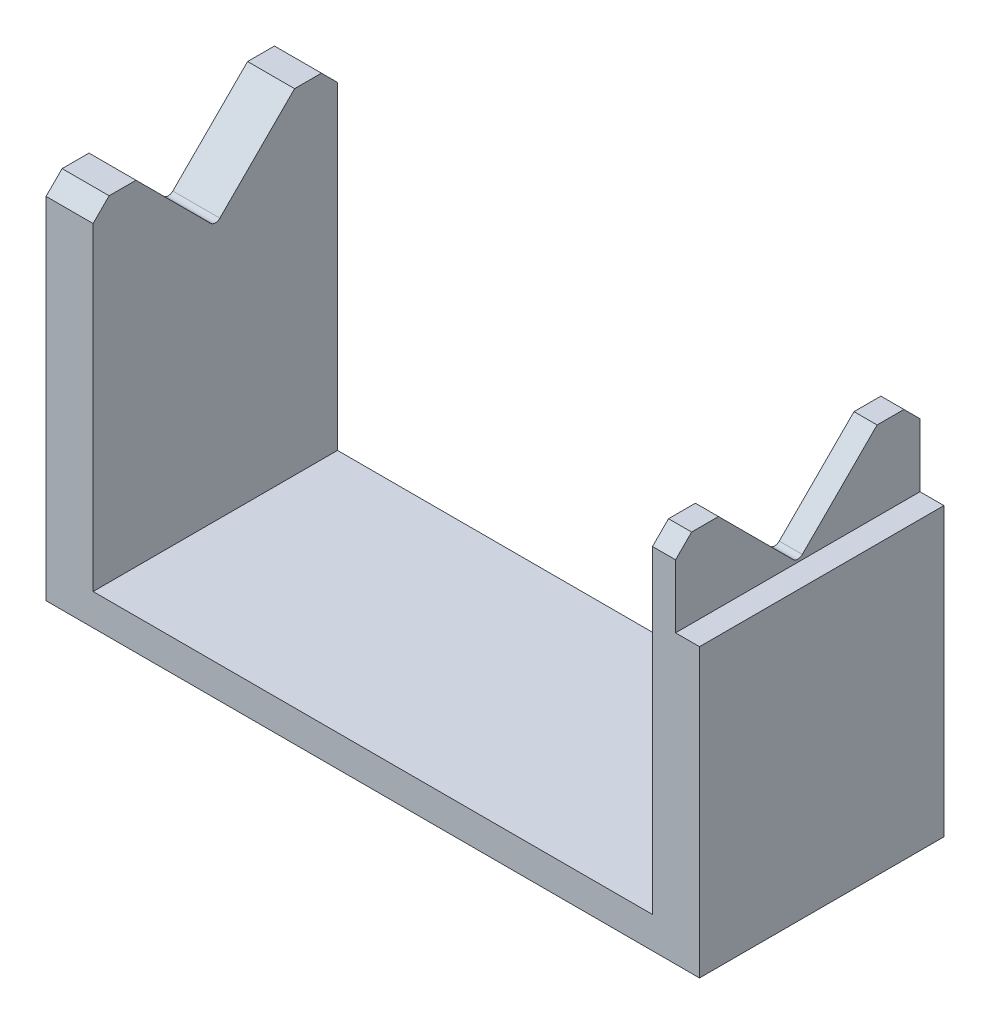
from build123d import *

# Parameters (mm, degrees)
ESBO_O1_W                = 101.86
ESBO_O1_H                = 38.1
RESSALTO_EXTRUS_O1_DEPTH = 57.09
ESBO_O2_W                = 87.2
ESBO_O2_H                = 52.18
CORTE_EXTRUS_O1_DEPTH    = 57.09
ESBO_O4_W                = 3.73
ESBO_O4_H                = 12.36
CORTE_EXTRUS_O2_DEPTH    = 57.09
CORTE_EXTRUS_O3_DEPTH    = 1000
FILETE1_R                = 1
CHANFRO1_SIZE            = 2.5


with BuildPart() as part:
    # Esboço1 → Ressalto-extrusão1 (new body)
    with BuildSketch(Plane(origin=(0, 0, 0), x_dir=(1, 0, 0), z_dir=(0, 1, 0))):
        Rectangle(ESBO_O1_W, ESBO_O1_H)
    extrude(amount=RESSALTO_EXTRUS_O1_DEPTH)

    # Esboço2 → Corte-extrusão1 (cut)
    with BuildSketch(Plane.XY.offset(19.05)):
        with Locations((0, 31)):
            Rectangle(ESBO_O2_W, ESBO_O2_H)
    extrude(amount=-CORTE_EXTRUS_O1_DEPTH, mode=Mode.SUBTRACT)

    # Esboço4 → Corte-extrusão2 (cut)
    with BuildSketch(Plane.XY.offset(19.05)):
        with Locations((49.065, 50.91)):
            Rectangle(ESBO_O4_W, ESBO_O4_H)
    extrude(amount=-CORTE_EXTRUS_O2_DEPTH, mode=Mode.SUBTRACT)

    # Esboço5 → Corte-extrusão3 (cut)
    with BuildSketch(Plane(origin=(47.2, 0, 0), x_dir=(0, 0, -1), z_dir=(1, 0, 0))):
        Polygon((0, 44.73), (-12.36, 57.09), (12.36, 57.09), align=None)
    extrude(amount=-CORTE_EXTRUS_O3_DEPTH, mode=Mode.SUBTRACT)

    # Filete1
    filete1_edges = [part.edges().sort_by_distance(p)[0] for p in [
        (-47.265, 44.73, 0),
        (45.4, 44.73, 0),
    ]]
    fillet(filete1_edges, radius=FILETE1_R)

    # Chanfro1
    chanfro1_edges = [part.edges().sort_by_distance(p)[0] for p in [
        (45.4, 57.09, 19.05),
        (-47.265, 57.09, -19.05),
        (45.4, 57.09, -19.05),
        (-47.265, 57.09, 19.05),
    ]]
    chamfer(chanfro1_edges, length=CHANFRO1_SIZE)


solid = part.part
